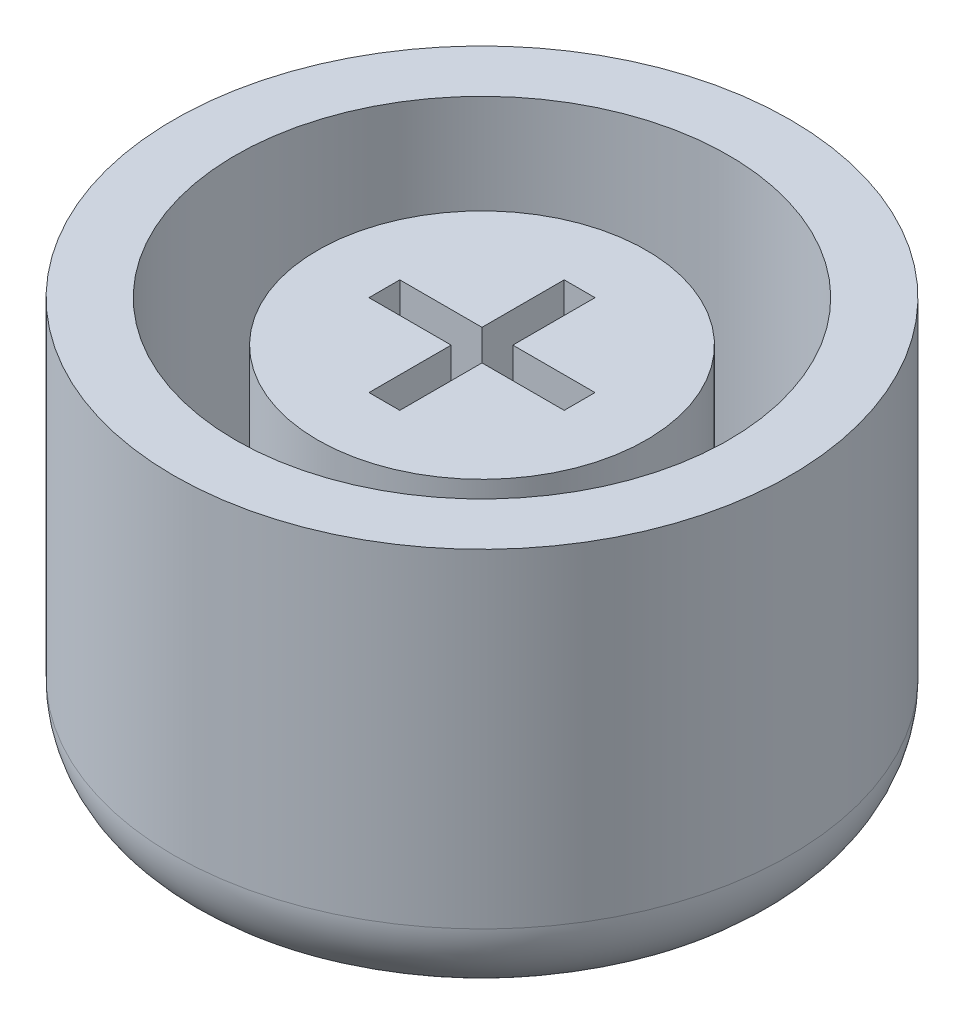
from build123d import *

# Parameters (mm, degrees)
SKETCH1_R           = 7.5
BOSS_EXTRUDE1_DEPTH = 10
SKETCH2_R           = 6
CUT_EXTRUDE1_DEPTH  = 8
SKETCH3_R           = 4
BOSS_EXTRUDE2_DEPTH = 7
CUT_EXTRUDE2_DEPTH  = 7
FILLET1_R           = 2
CUT_EXTRUDE3_DEPTH  = 1


with BuildPart() as part:
    # Sketch1 → Boss-Extrude1 (new body)
    with BuildSketch(Plane(origin=(0, 0, 0), x_dir=(1, 0, 0), z_dir=(0, 1, 0))):
        Circle(SKETCH1_R)
    extrude(amount=BOSS_EXTRUDE1_DEPTH)

    # Sketch2 → Cut-Extrude1 (cut)
    with BuildSketch(Plane(origin=(0, 10, 0), x_dir=(1, 0, 0), z_dir=(0, 1, 0))):
        Circle(SKETCH2_R)
    extrude(amount=-CUT_EXTRUDE1_DEPTH, mode=Mode.SUBTRACT)

    # Sketch3 → Boss-Extrude2 (add)
    with BuildSketch(Plane(origin=(0, 2, 0), x_dir=(1, 0, 0), z_dir=(0, 1, 0))):
        Circle(SKETCH3_R)
    extrude(amount=BOSS_EXTRUDE2_DEPTH)

    # Sketch4 → Cut-Extrude2 (cut)
    with BuildSketch(Plane(origin=(0, 9, 0), x_dir=(1, 0, 0), z_dir=(0, 1, 0))):
        Polygon((-0.375, 2.375), (0.375, 2.375), (0.375, 0.375), (2.375, 0.375), (2.375, -0.375), (0.375, -0.375), (0.375, -2.375), (-0.375, -2.375), (-0.375, -0.375), (-2.375, -0.375), (-2.375, 0.375), (-0.375, 0.375), align=None)
    extrude(amount=-CUT_EXTRUDE2_DEPTH, mode=Mode.SUBTRACT)

    # Fillet1
    fillet1_edges = [part.edges().sort_by_distance(p)[0] for p in [
        (-7.5, 0, 0),
    ]]
    fillet(fillet1_edges, radius=FILLET1_R)

    # Sketch5 → Cut-Extrude3 (cut)
    with BuildSketch(Plane.XZ):
        with BuildLine():
            Line((0.76193273, 2.148499301), (0.153359012, 1.653507314))
            add(Edge.make_bspline(
                [(0.153359012, 1.653507314), (0.083021889, 1.747844891), (-0.052789724, 1.929998185), (-0.276057522, 2.172317821), (-0.506764689, 2.37481882), (-0.74476501, 2.538546352), (-0.991609879, 2.666270917), (-1.2506838, 2.754269191), (-1.521360754, 2.809892448), (-1.706212335, 2.816714127), (-1.799966309, 2.820173981)],
                knots=[0, 0, 0, 0, 0.000352845, 0.000681296, 0.000986409, 0.001271892, 0.001545947, 0.001817339, 0.002090416, 0.002371457, 0.002371457, 0.002371457, 0.002371457], degree=3))
            add(Edge.make_bspline(
                [(-1.799966309, 2.820173981), (-1.8472193, 2.819084493), (-1.941092049, 2.816920117), (-2.081489858, 2.799772577), (-2.219467955, 2.7697109), (-2.356832992, 2.730930294), (-2.491166939, 2.678541876), (-2.624330259, 2.614866042), (-2.755091919, 2.539131082), (-2.884086982, 2.453735757), (-3.008867611, 2.358894363), (-3.127040978, 2.252959225), (-3.238398514, 2.138146926), (-3.345237173, 2.015644776), (-3.442102855, 1.882374476), (-3.53410476, 1.741172117), (-3.619762908, 1.591086027), (-3.697704491, 1.431764117), (-3.768032023, 1.265280417), (-3.827600945, 1.092553945), (-3.880431255, 0.915066326), (-3.922172538, 0.731401823), (-3.954007185, 0.541700698), (-3.978105901, 0.34665531), (-3.992410644, 0.145845603), (-3.993782767, 0.010100778), (-3.994477527, -0.058632109)],
                knots=[0, 0, 0, 0, 0.000141738, 0.000281576, 0.000423487, 0.000565058, 0.000709325, 0.000855462, 0.001007474, 0.001162262, 0.00131932, 0.001477226, 0.001637867, 0.001798936, 0.001964407, 0.00213165, 0.00230436, 0.002482461, 0.002663459, 0.002846171, 0.003030314, 0.003218764, 0.003410794, 0.003607158, 0.003808169, 0.004014342, 0.004014342, 0.004014342, 0.004014342], degree=3))
            add(Edge.make_bspline(
                [(-3.994477527, -0.058632109), (-3.992796896, -0.161081487), (-3.989496709, -0.362257194), (-3.957585853, -0.656533367), (-3.908082983, -0.937185558), (-3.836067009, -1.202995258), (-3.745344728, -1.454773195), (-3.633616632, -1.692293227), (-3.50215723, -1.916003329), (-3.349386327, -2.121930588), (-3.184138653, -2.309195071), (-3.007734399, -2.472739485), (-2.824038891, -2.613741277), (-2.628570682, -2.725739146), (-2.426094857, -2.815957121), (-2.2135749, -2.876703087), (-1.993107808, -2.916628066), (-1.842679498, -2.921130195), (-1.766312463, -2.923415763)],
                knots=[0, 0, 0, 0, 0.000307248, 0.000603331, 0.000886907, 0.00116141, 0.001428448, 0.001688771, 0.001947777, 0.002205519, 0.002456818, 0.002695945, 0.002926194, 0.003149869, 0.003370271, 0.00358947, 0.003811472, 0.004040386, 0.004040386, 0.004040386, 0.004040386], degree=3))
            add(Edge.make_bspline(
                [(-1.766312463, -2.923415763), (-1.676295231, -2.919933651), (-1.496923149, -2.912995051), (-1.23291743, -2.856268171), (-0.977532433, -2.763811379), (-0.730841631, -2.635206497), (-0.493762277, -2.468814466), (-0.266137061, -2.266254801), (-0.046046579, -2.028245281), (0.086339727, -1.849256363), (0.154761255, -1.756749096)],
                knots=[0, 0, 0, 0, 0.000269847, 0.000537709, 0.000806065, 0.001082652, 0.001369729, 0.001672734, 0.001995241, 0.002340218, 0.002340218, 0.002340218, 0.002340218], degree=3))
            Line((0.154761255, -1.756749096), (0.76193273, -2.251741083))
            add(Edge.make_bspline(
                [(0.76193273, -2.251741083), (0.72633948, -2.30935273), (0.655939117, -2.423303572), (0.536203628, -2.582439908), (0.413755054, -2.735348366), (0.281248095, -2.875961564), (0.144334802, -3.009421933), (-0.002753471, -3.128946981), (-0.154113218, -3.242566064), (-0.313741066, -3.344209321), (-0.47884491, -3.435555613), (-0.649930551, -3.514657106), (-0.825688617, -3.58142867), (-1.006791058, -3.6371329), (-1.193130146, -3.678276393), (-1.384506371, -3.709636017), (-1.581310684, -3.728247719), (-1.71439018, -3.73014694), (-1.781737142, -3.731108071)],
                knots=[0, 0, 0, 0, 0.00020305, 0.000401614, 0.000596965, 0.000790439, 0.000980855, 0.00117009, 0.001358555, 0.001548377, 0.001737284, 0.001924246, 0.002113315, 0.002300949, 0.002492133, 0.002685317, 0.002882475, 0.003084476, 0.003084476, 0.003084476, 0.003084476], degree=3))
            add(Edge.make_bspline(
                [(-1.781737142, -3.731108071), (-1.842074184, -3.7305756), (-1.961553247, -3.729521206), (-2.137923732, -3.71279446), (-2.309858419, -3.689618118), (-2.476608757, -3.655950351), (-2.638712579, -3.612469715), (-2.795623318, -3.558447861), (-2.949000003, -3.498282105), (-3.095138884, -3.42321804), (-3.238507769, -3.343103216), (-3.376207643, -3.250971858), (-3.509647175, -3.150362891), (-3.637407214, -3.038712428), (-3.761071425, -2.918412916), (-3.878768699, -2.787106832), (-3.992554172, -2.647530973), (-4.062804057, -2.548496586), (-4.098243552, -2.498535955)],
                knots=[0, 0, 0, 0, 0.000180938, 0.000358293, 0.00053102, 0.000701246, 0.000868261, 0.001034105, 0.001198933, 0.00136198, 0.001526515, 0.001691414, 0.001858564, 0.002027544, 0.002200083, 0.002375812, 0.002556266, 0.002739981, 0.002739981, 0.002739981, 0.002739981], degree=3))
            add(Edge.make_bspline(
                [(-4.098243552, -2.498535955), (-4.154965431, -2.411120863), (-4.268388047, -2.236323258), (-4.41062105, -1.956883044), (-4.532186164, -1.66548425), (-4.630023951, -1.359862868), (-4.706624592, -1.041542818), (-4.763539503, -0.71050925), (-4.795497708, -0.365891988), (-4.799919185, -0.131612529), (-4.802169834, -0.012358071)],
                knots=[0, 0, 0, 0, 0.000312436, 0.000624756, 0.000939074, 0.001258801, 0.00158632, 0.001920587, 0.002265647, 0.002623395, 0.002623395, 0.002623395, 0.002623395], degree=3))
            add(Edge.make_bspline(
                [(-4.802169834, -0.012358071), (-4.799290096, 0.113002264), (-4.793623732, 0.359669518), (-4.754524465, 0.721897457), (-4.686849807, 1.068873905), (-4.59281977, 1.401078467), (-4.472489287, 1.718607923), (-4.324303008, 2.021058271), (-4.148172224, 2.307157933), (-3.949177133, 2.576747821), (-3.729354306, 2.822297275), (-3.493438785, 3.038039566), (-3.243803001, 3.221037792), (-2.979450649, 3.369270799), (-2.701317459, 3.485093074), (-2.409184706, 3.568123667), (-2.1031702, 3.61816349), (-1.894570903, 3.624600692), (-1.78874836, 3.627866288)],
                knots=[0, 0, 0, 0, 0.000376063, 0.000739966, 0.001091423, 0.00143543, 0.001774507, 0.002108762, 0.00244425, 0.002781074, 0.003112728, 0.003431358, 0.003738478, 0.004039207, 0.004338424, 0.004640248, 0.004948468, 0.005265821, 0.005265821, 0.005265821, 0.005265821], degree=3))
            add(Edge.make_bspline(
                [(-1.78874836, 3.627866288), (-1.720466596, 3.626920041), (-1.58598664, 3.625056421), (-1.386854395, 3.606321924), (-1.193190452, 3.574900139), (-1.003714489, 3.534388599), (-0.821455099, 3.47648457), (-0.642960212, 3.411572099), (-0.471194085, 3.330801183), (-0.304060163, 3.240144161), (-0.144298794, 3.137287445), (0.008959845, 3.025031091), (0.154366171, 2.902999949), (0.293190826, 2.772452489), (0.421247711, 2.629924683), (0.544566768, 2.47994694), (0.657602086, 2.318358282), (0.726974367, 2.205414429), (0.76193273, 2.148499301)],
                knots=[0, 0, 0, 0, 0.000204804, 0.000403359, 0.000599312, 0.000793233, 0.000983959, 0.001172533, 0.001362629, 0.001552766, 0.001742588, 0.001932181, 0.002122313, 0.002311762, 0.002503336, 0.002696714, 0.002893957, 0.003094321, 0.003094321, 0.003094321, 0.003094321], degree=3))
        make_face()
        with BuildLine():
            add(Edge.make_bspline(
                [(4.17218914, 1.967609878), (4.170594695, 1.912422702), (4.167464674, 1.804085899), (4.150059978, 1.643694478), (4.115028198, 1.489901567), (4.071304332, 1.339987925), (4.011046327, 1.197233813), (3.941731121, 1.057934786), (3.854905856, 0.926992698), (3.759083616, 0.801308142), (3.654217624, 0.684948349), (3.537676654, 0.584691228), (3.414460918, 0.499347572), (3.284472532, 0.427460204), (3.145293669, 0.374874104), (2.99946787, 0.334834477), (2.845395927, 0.31277327), (2.740562265, 0.309181363), (2.687213178, 0.307353468)],
                knots=[0, 0, 0, 0, 0.000165613, 0.000325112, 0.000482987, 0.000638251, 0.00079293, 0.000947202, 0.001104335, 0.001263358, 0.001421165, 0.001573262, 0.001723407, 0.001870235, 0.002017624, 0.00216865, 0.002323132, 0.002483209, 0.002483209, 0.002483209, 0.002483209], degree=3))
            add(Edge.make_bspline(
                [(2.687213178, 0.307353468), (2.639428987, 0.308439079), (2.544643644, 0.310592513), (2.405985019, 0.335690152), (2.273030805, 0.37369219), (2.145187793, 0.425350531), (2.024790736, 0.495381963), (1.908732478, 0.577897413), (1.800461921, 0.677983669), (1.697571397, 0.79009231), (1.60440474, 0.914251741), (1.522580079, 1.046539567), (1.454006555, 1.185680899), (1.397128639, 1.331429851), (1.354020503, 1.484147149), (1.323570572, 1.644160149), (1.302761164, 1.810478608), (1.301190228, 1.924075293), (1.300394268, 1.981632314)],
                knots=[0, 0, 0, 0, 0.000143201, 0.000284055, 0.000421195, 0.000557646, 0.00069644, 0.000838094, 0.000984015, 0.00113786, 0.00129407, 0.001448953, 0.001603848, 0.001758788, 0.001917694, 0.002079123, 0.00224714, 0.002419708, 0.002419708, 0.002419708, 0.002419708], degree=3))
            add(Edge.make_bspline(
                [(1.300394268, 1.981632314), (1.301999566, 2.036822329), (1.305177901, 2.146093271), (1.322575862, 2.306811264), (1.355875818, 2.461383321), (1.400033739, 2.609957466), (1.458751955, 2.752640479), (1.527487289, 2.890466201), (1.613949939, 3.019551839), (1.707301835, 3.143784051), (1.811623492, 3.256544057), (1.923074616, 3.354833619), (2.038453608, 3.440581075), (2.160441282, 3.509402302), (2.288012982, 3.561344765), (2.419990134, 3.599545939), (2.557254219, 3.624623316), (2.651113222, 3.62677935), (2.698431127, 3.627866288)],
                knots=[0, 0, 0, 0, 0.000165613, 0.000327898, 0.000484108, 0.000639372, 0.000792223, 0.000946495, 0.001100512, 0.00125757, 0.001412364, 0.001560372, 0.00170285, 0.001842864, 0.001979314, 0.002115108, 0.00225458, 0.00239638, 0.00239638, 0.00239638, 0.00239638], degree=3))
            add(Edge.make_bspline(
                [(2.698431127, 3.627866288), (2.750846534, 3.62601906), (2.854283858, 3.622373712), (3.006029716, 3.600458116), (3.150298314, 3.56054078), (3.287226646, 3.50558644), (3.416870465, 3.435338438), (3.538904799, 3.348305176), (3.653294659, 3.246002567), (3.759697634, 3.129741496), (3.854403577, 3.002697563), (3.941853802, 2.871754588), (4.010655393, 2.732676154), (4.071652249, 2.590700158), (4.114749175, 2.441506499), (4.150250713, 2.288298884), (4.167316338, 2.129250883), (4.170553781, 2.021858133), (4.17218914, 1.967609878)],
                knots=[0, 0, 0, 0, 0.000157276, 0.000310372, 0.000458692, 0.000605292, 0.000752119, 0.000899968, 0.001053915, 0.001211722, 0.00137186, 0.001528993, 0.001683265, 0.001836649, 0.001991912, 0.002148418, 0.002307917, 0.002470728, 0.002470728, 0.002470728, 0.002470728], degree=3))
        make_face()
        with BuildLine():
            add(Edge.make_bspline(
                [(3.364496832, 1.959196417), (3.362128617, 2.024809463), (3.357555511, 2.151510542), (3.320988947, 2.332951761), (3.25930418, 2.496987671), (3.172574477, 2.639282817), (3.070162971, 2.756214951), (2.958000902, 2.846525431), (2.83226504, 2.899995142), (2.744697415, 2.906626351), (2.701235614, 2.90991757)],
                knots=[0, 0, 0, 0, 0.000196719, 0.000379872, 0.00055253, 0.000719909, 0.000876885, 0.001016843, 0.00114887, 0.001278969, 0.001278969, 0.001278969, 0.001278969], degree=3))
            add(Edge.make_bspline(
                [(2.701235614, 2.90991757), (2.667547461, 2.906216075), (2.59703, 2.89846795), (2.494227532, 2.845682426), (2.394827192, 2.761692738), (2.298256221, 2.649169296), (2.213106289, 2.510475793), (2.151128146, 2.347570477), (2.114835433, 2.164115167), (2.110404124, 2.035089512), (2.108086576, 1.967609878)],
                knots=[0, 0, 0, 0, 0.000100971, 0.000211357, 0.000339913, 0.000490032, 0.000654286, 0.000825635, 0.001010162, 0.00121248, 0.00121248, 0.00121248, 0.00121248], degree=3))
            add(Edge.make_bspline(
                [(2.108086576, 1.967609878), (2.110408715, 1.901056322), (2.114862519, 1.773408296), (2.151421562, 1.591490032), (2.213099289, 1.428165389), (2.299937924, 1.289497639), (2.395569523, 1.174656455), (2.495639786, 1.092294012), (2.595483784, 1.036185694), (2.665108187, 1.02882506), (2.698431127, 1.025302186)],
                knots=[0, 0, 0, 0, 0.000199518, 0.000382671, 0.00055402, 0.000720202, 0.000871385, 0.000999941, 0.001108431, 0.00120802, 0.00120802, 0.00120802, 0.00120802], degree=3))
            add(Edge.make_bspline(
                [(2.698431127, 1.025302186), (2.741474785, 1.028536547), (2.828238838, 1.035056122), (2.952341043, 1.089688984), (3.066459107, 1.176805091), (3.168150807, 1.295088901), (3.255916407, 1.435956821), (3.319113623, 1.597023414), (3.35791829, 1.773197709), (3.362257678, 1.89588759), (3.364496832, 1.959196417)],
                knots=[0, 0, 0, 0, 0.000128709, 0.000259441, 0.000399666, 0.000556642, 0.000724753, 0.000895309, 0.001073261, 0.001262984, 0.001262984, 0.001262984, 0.001262984], degree=3))
        make_face(mode=Mode.SUBTRACT)
    extrude(amount=-CUT_EXTRUDE3_DEPTH, mode=Mode.SUBTRACT)


solid = part.part
